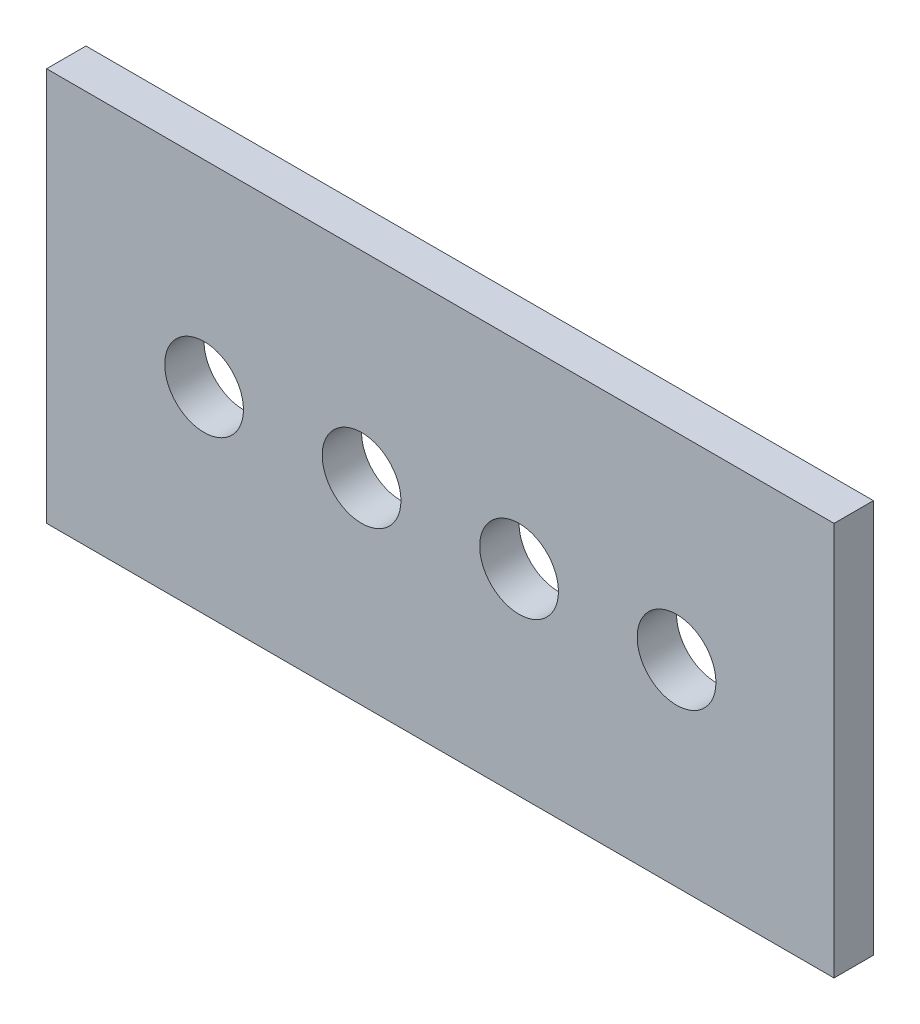
from build123d import *

# Parameters (mm, degrees)
SKETCH1_W           = 100
SKETCH1_H           = 50
SKETCH1_R           = 5
BOSS_EXTRUDE1_DEPTH = 5


with BuildPart() as part:
    # Sketch1 → Boss-Extrude1 (new body)
    with BuildSketch(Plane.XY):
        with Locations((50, 25)):
            Rectangle(SKETCH1_W, SKETCH1_H)
        with Locations((20, 25)):
            Circle(SKETCH1_R, mode=Mode.SUBTRACT)
        with Locations((40, 25)):
            Circle(SKETCH1_R, mode=Mode.SUBTRACT)
        with Locations((60, 25)):
            Circle(SKETCH1_R, mode=Mode.SUBTRACT)
        with Locations((80, 25)):
            Circle(SKETCH1_R, mode=Mode.SUBTRACT)
    extrude(amount=BOSS_EXTRUDE1_DEPTH)


solid = part.part
